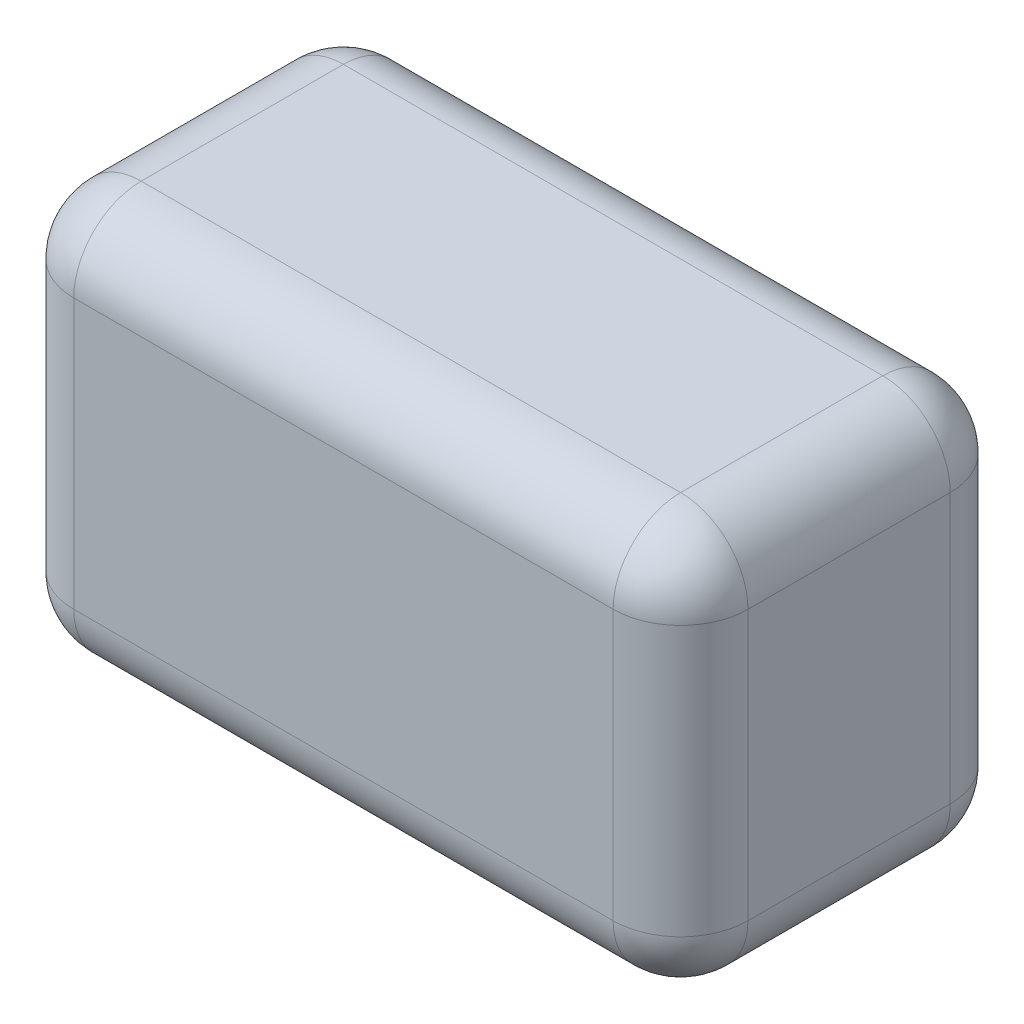
from build123d import *

# Parameters (mm, degrees)
SKETCH1_W           = 254
SKETCH1_H           = 127
BOSS_EXTRUDE1_DEPTH = 152.4
FILLET1_R           = 25.4
SKETCH3_R           = 3.81
CUT_EXTRUDE1_DEPTH  = 8.89


with BuildPart() as part:
    # Sketch1 → Boss-Extrude1 (new body)
    with BuildSketch(Plane(origin=(0, 0, 0), x_dir=(1, 0, 0), z_dir=(0, 1, 0))):
        Rectangle(SKETCH1_W, SKETCH1_H)
    extrude(amount=BOSS_EXTRUDE1_DEPTH)

    # Fillet1
    fillet1_edges = [part.edges().sort_by_distance(p)[0] for p in [
        (-127, 152.4, 0),
        (0, 152.4, 63.5),
        (127, 152.4, 0),
        (0, 0, 63.5),
        (-127, 0, 0),
        (0, 0, -63.5),
        (127, 0, 0),
        (127, 76.2, 63.5),
        (-127, 76.2, 63.5),
        (-127, 76.2, -63.5),
        (127, 76.2, -63.5),
        (0, 152.4, -63.5),
    ]]
    fillet(fillet1_edges, radius=FILLET1_R)

    # Sketch3 → Cut-Extrude1 (cut)
    with BuildSketch(Plane.XZ):
        with Locations((-50.8, 0)):
            Circle(SKETCH3_R)
    cut_extrude1 = extrude(amount=-CUT_EXTRUDE1_DEPTH, mode=Mode.SUBTRACT)

    # Mirror1: Cut-Extrude1 across plane
    add(cut_extrude1.mirror(Plane(origin=(0, 0, 0), x_dir=(0, 0, 1), z_dir=(1, 0, 0))), mode=Mode.SUBTRACT)


solid = part.part
